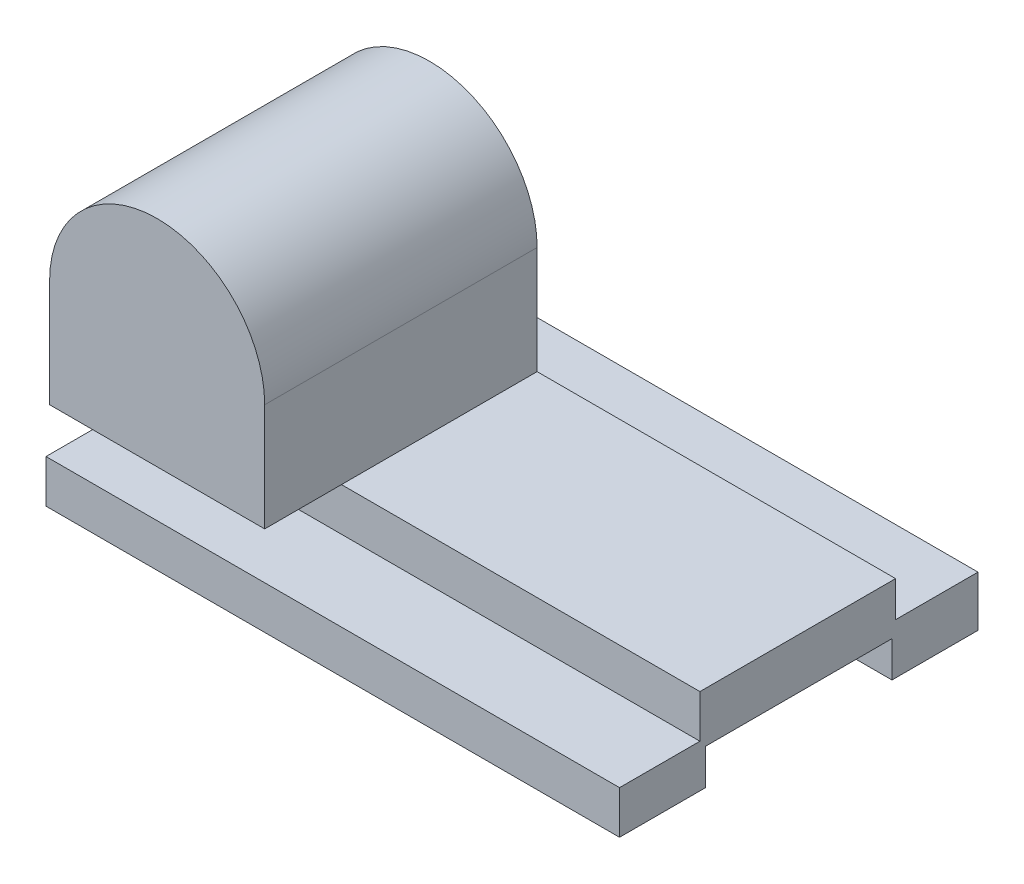
from build123d import *

# Parameters (mm, degrees)
BOSS_EXTRUDE1_DEPTH = 160
SKETCH2_R           = 15
BOSS_EXTRUDE2_DEPTH = 76


with BuildPart() as part:
    # Sketch1 → Boss-Extrude1 (new body)
    with BuildSketch(Plane(origin=(0, 0, 0), x_dir=(0, 0, -1), z_dir=(1, 0, 0))):
        Polygon((-26, -5), (-50, -5), (-50, 7), (-27.572519084, 7), (-27.572519084, 19), (27.007633588, 19), (27.007633588, 9.076335878), (50, 9.076335878), (50, -5), (26, -5), (26, 5), (-26, 5), align=None)
    extrude(amount=-BOSS_EXTRUDE1_DEPTH)

    # Sketch2 → Boss-Extrude2 (add)
    with BuildSketch(Plane(origin=(0, 0, -27.007633588), x_dir=(-1, 0, 0), z_dir=(0, 0, -1))):
        with BuildLine():
            Line((100, 19), (160, 19))
            Line((160, 19), (160, 49))
            ThreePointArc((160, 49), (130, 79), (100, 49))
            Line((100, 49), (100, 19))
        make_face()
        with Locations((130, 49)):
            Circle(SKETCH2_R, mode=Mode.SUBTRACT)
        with Locations((130, 49)):
            Circle(SKETCH2_R)
    extrude(amount=-BOSS_EXTRUDE2_DEPTH)


solid = part.part
